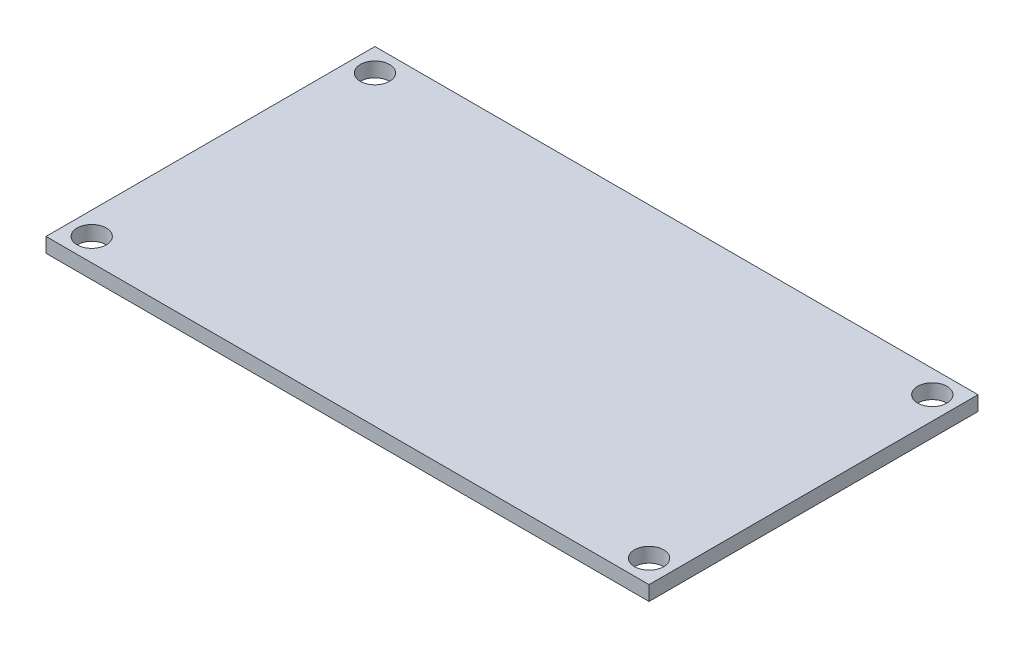
from build123d import *

# Parameters (mm, degrees)
SKETCH1_W            = 66
SKETCH1_H            = 36
BOSS_EXTRUDE1_DEPTH  = 1.6
M3_CLEARANCE_HOLE1_D = 3.2
MIRROR2_COPY_1_D     = 3.2


with BuildPart() as part:
    # Sketch1 → Boss-Extrude1 (new body)
    with BuildSketch(Plane(origin=(0, 0, 0), x_dir=(1, 0, 0), z_dir=(0, 1, 0))):
        Rectangle(SKETCH1_W, SKETCH1_H)
    extrude(amount=BOSS_EXTRUDE1_DEPTH)

    # M3 Clearance Hole1 (through all)
    with Locations(Plane(origin=(0, 1.6, 0), x_dir=(1, 0, 0), z_dir=(0, 1, 0))):
        with Locations((-30.5, 15.5)):
            m3_clearance_hole1 = Hole(M3_CLEARANCE_HOLE1_D / 2)

    # Mirror1: M3 Clearance Hole1 across plane
    add(m3_clearance_hole1.mirror(Plane(origin=(0, 0, 0), x_dir=(0, 0, 1), z_dir=(1, 0, 0))), mode=Mode.SUBTRACT)

    # Mirror2: M3 Clearance Hole1 across plane
    add(m3_clearance_hole1.mirror(Plane.XY), mode=Mode.SUBTRACT)

    # Mirror2 copy 1 (through all)
    with Locations(Plane(origin=(0, 1.6, 0), x_dir=(-1, 0, 0), z_dir=(0, 1, 0))):
        with Locations((-30.5, 15.5)):
            Hole(MIRROR2_COPY_1_D / 2)


solid = part.part
